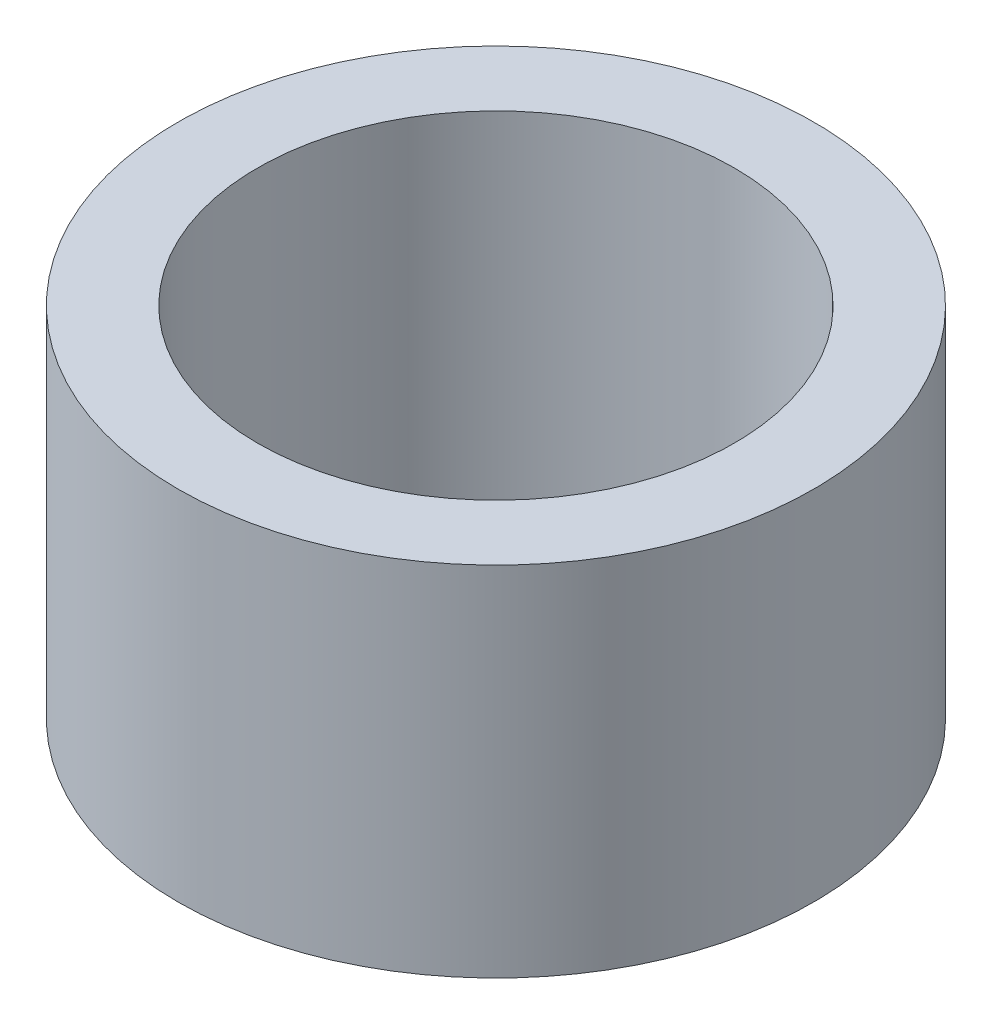
from build123d import *

# Parameters (mm, degrees)
SKETCH1_R           = 4
SKETCH1_R_2         = 3
BOSS_EXTRUDE2_DEPTH = 4.5


with BuildPart() as part:
    # Sketch1 → Boss-Extrude2 (new body)
    with BuildSketch(Plane(origin=(0, 0, 0), x_dir=(1, 0, 0), z_dir=(0, 1, 0))):
        Circle(SKETCH1_R)
        Circle(SKETCH1_R_2, mode=Mode.SUBTRACT)
    extrude(amount=BOSS_EXTRUDE2_DEPTH)


solid = part.part
